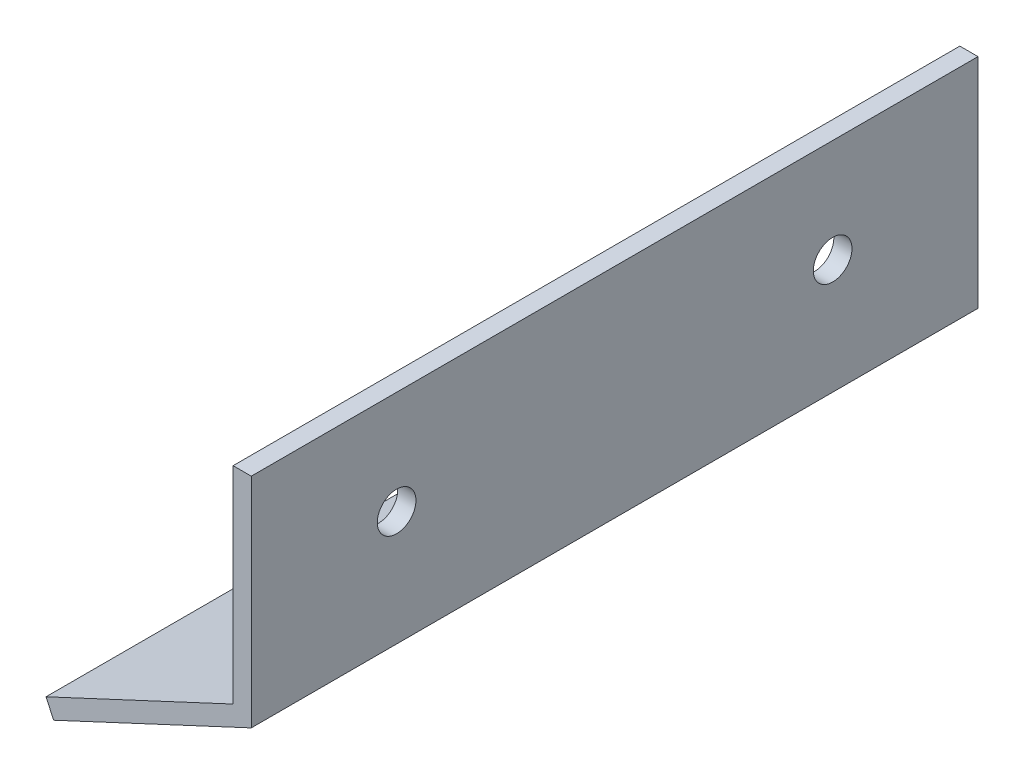
from build123d import *

# Parameters (mm, degrees)
BOSS_EXTRUDE1_DEPTH               = 63.5
F_1_4_CLEARANCE_HOLE1_D           = 6.7564
F_1_4_CLEARANCE_HOLE1_ON_FACE_2_D = 6.7564


with BuildPart() as part:
    # Sketch1 → Boss-Extrude1 (new body, symmetric)
    with BuildSketch(Plane.XY):
        Polygon((0, 0), (0, 38.1), (-3.175, 38.1), (-3.175, 2.022698078), (-35.872139667, -13.224228548), (-34.530326686, -16.101755772), align=None)
    extrude(amount=BOSS_EXTRUDE1_DEPTH, both=True)

    # 1/4 Clearance Hole1 (through all)
    with Locations(Plane(origin=(-3.175, 20.061349039, -38.1), x_dir=(0, 0, -1), z_dir=(-1, 0, 0))):
        with Locations((0, 0), (-76.2, 0)):
            Hole(F_1_4_CLEARANCE_HOLE1_D / 2)

    # 1/4 Clearance Hole1 on face 2 (through all)
    with Locations(Plane(origin=(-19.523569834, -5.600765235, -38.1), x_dir=(0.906307925, 0.422617965, 0), z_dir=(-0.422617965, 0.906307925, 0))):
        with Locations((0, 0), (0, -76.2)):
            Hole(F_1_4_CLEARANCE_HOLE1_ON_FACE_2_D / 2)


solid = part.part
